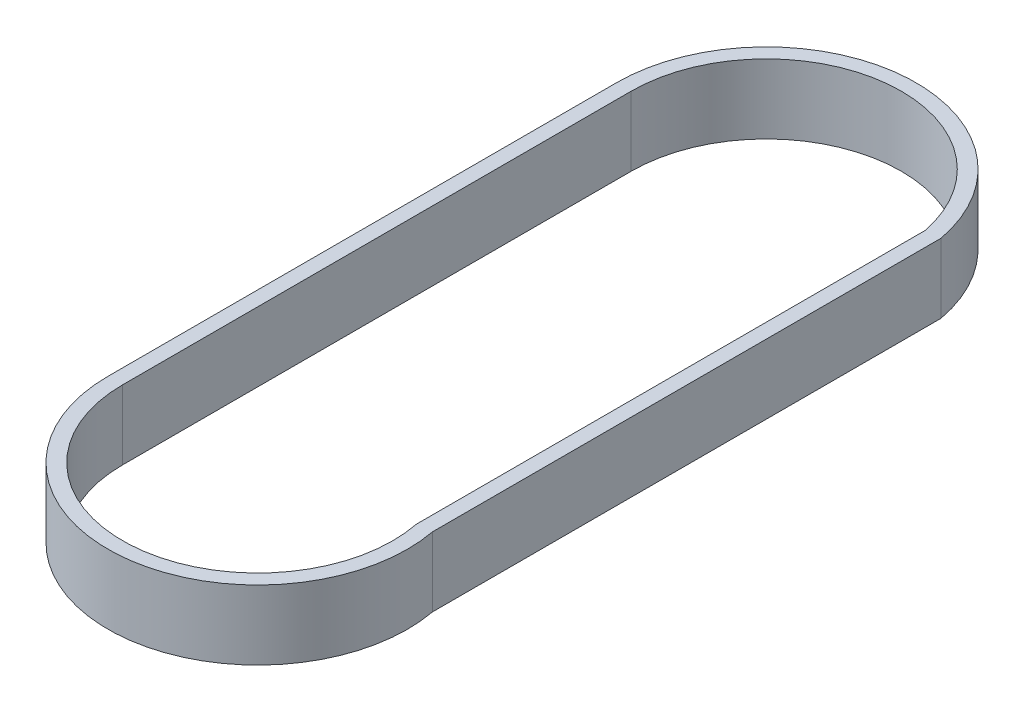
from build123d import *

# Parameters (mm, degrees)
BOSS_EXTRUDE1_DEPTH = 14.9999954


with BuildPart() as part:
    # Sketch1 → Boss-Extrude1 (new body)
    with BuildSketch(Plane(origin=(0, 0, 0), x_dir=(1, 0, 0), z_dir=(0, 1, 0))):
        with BuildLine():
            Line((61.042657366, -51.944352263), (61.042657366, 58.037647737))
            ThreePointArc((61.042657366, 58.037647737), (26.219379981, 84.328584265), (-3.175, 52.081965576))
            Line((-3.175, 52.081965576), (-3.175, -57.900034424))
            ThreePointArc((-3.175, -57.900034424), (32.200620019, -90.146653113), (61.042657366, -51.944352263))
        make_face()
        with BuildLine():
            Line((0, 52.081965576), (0, -57.900034424))
            ThreePointArc((0, -57.900034424), (32.05024016, -86.971620824), (57.867657366, -52.246471452))
            Line((57.867657366, -52.246471452), (57.867657366, 57.735528548))
            ThreePointArc((57.867657366, 57.735528548), (26.36975984, 81.153551976), (0, 52.081965576))
        make_face(mode=Mode.SUBTRACT)
    extrude(amount=BOSS_EXTRUDE1_DEPTH)


solid = part.part
